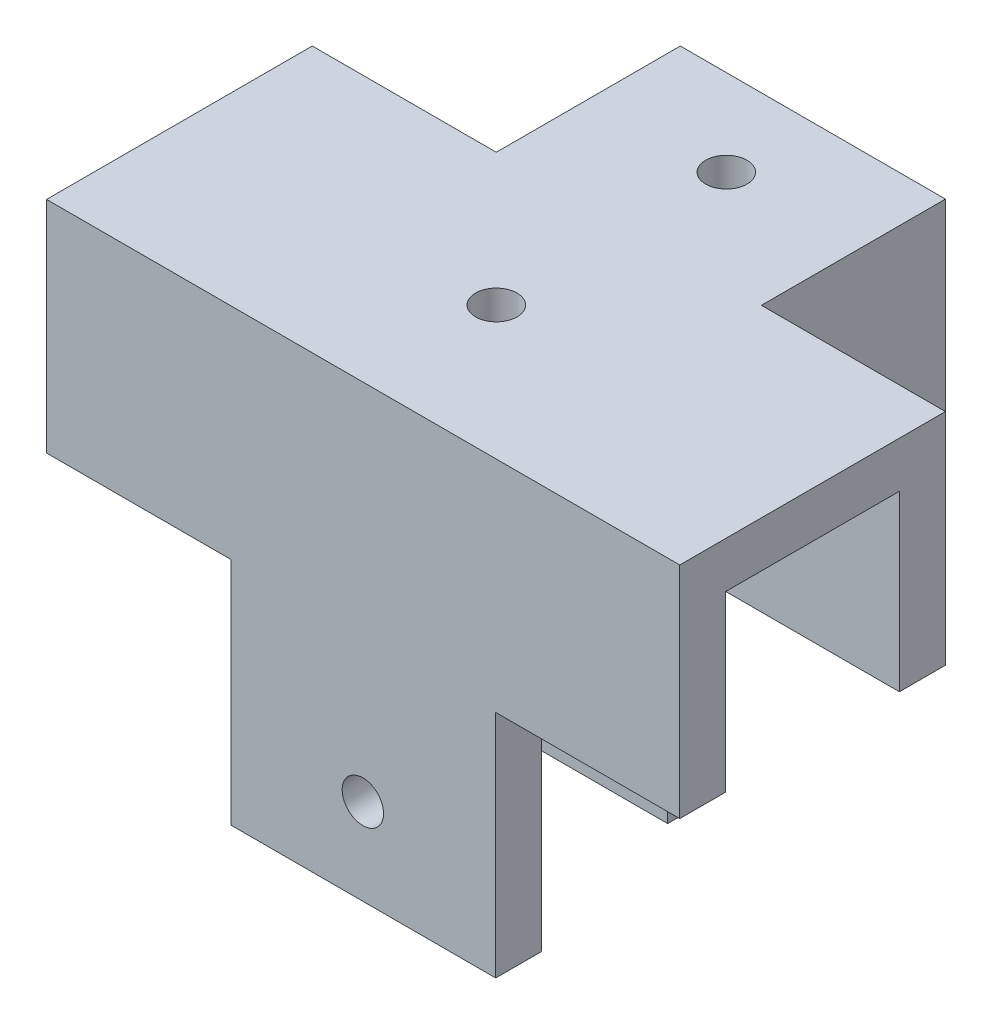
from build123d import *

# Parameters (mm, degrees)
EXTRUDE_1_DEPTH     = 15.1
EXTRUDE_1_2_DEPTH   = 15.1
SKETCH_1_W          = 55.05
SKETCH_1_H          = 4
EXTRUDE_1_3_DEPTH   = 15.1
SKETCH_2_W          = 4
SKETCH_2_H          = 16
SKETCH_2_W_2        = 19.05
EXTRUDE_2_DEPTH     = 4
EXTRUDE_3_DEPTH     = 20
SKETCH_4_R          = 1.8
CUT_EXTRUDE_1_DEPTH = 20
SKETCH_5_R          = 1.8
CUT_EXTRUDE_2_DEPTH = 27


with BuildPart() as part:
    # 草图1 → 凸台-拉伸1 (new body)
    with BuildSketch(Plane(origin=(0, 0, 0), x_dir=(1, 0, 0), z_dir=(0, 1, 0))):
        Polygon((-6.030769231, 9.384615385), (-22.030769231, 9.384615385), (-22.030769231, 5.384615385), (-6.030769231, 5.384615385), (-2.030769231, 5.384615385), (-2.030769231, 9.384615385), (-2.030769231, 25.384615385), (-6.030769231, 25.384615385), align=None)
    extrude(amount=EXTRUDE_1_DEPTH)



with BuildPart() as body_2:
    # 草图1 → Extrude 1 2 (new body)
    with BuildSketch(Plane(origin=(0, 0, 0), x_dir=(1, 0, 0), z_dir=(0, 1, 0))):
        Polygon((22.665384615, 5.384615385), (33.019230769, 5.384615385), (33.019230769, 9.384615385), (17.019230769, 9.384615385), (17.019230769, 25.384615385), (13.019230769, 25.384615385), (13.019230769, 8.769230769), (13.019230769, 5.384615385), align=None)
    extrude(amount=EXTRUDE_1_2_DEPTH)


with BuildPart() as body_3:
    # 草图1 → Extrude 1 3 (new body)
    with BuildSketch(Plane(origin=(0, 0, 0), x_dir=(1, 0, 0), z_dir=(0, 1, 0))):
        with Locations((5.494230769, -11.715384615)):
            Rectangle(SKETCH_1_W, SKETCH_1_H)
    extrude(amount=EXTRUDE_1_3_DEPTH)


with BuildPart() as part_1:
    add(part.part)

    add(body_2.part)  # 凸台-拉伸2 merges body 2

    add(body_3.part)  # 凸台-拉伸2 merges body 3
    # 草图2 → 凸台-拉伸2 (add)
    with BuildSketch(Plane(origin=(0, 15.1, 0), x_dir=(1, 0, 0), z_dir=(0, 1, 0))):
        with Locations((-4.030769231, 17.384615385)):
            Rectangle(SKETCH_2_W, SKETCH_2_H)
        with Locations((7.494230769, 17.384615385)):
            Rectangle(SKETCH_2_W_2, SKETCH_2_H)
        Polygon((-2.030769231, 5.384615385), (-22.030769231, 5.384615385), (-22.030769231, -13.715384615), (33.019230769, -13.715384615), (33.019230769, 9.384615385), (17.019230769, 9.384615385), (-2.030769231, 9.384615385), align=None)
        Polygon((-6.030769231, 9.384615385), (-22.030769231, 9.384615385), (-22.030769231, 5.384615385), (-2.030769231, 5.384615385), (-2.030769231, 9.384615385), align=None)
    extrude(amount=EXTRUDE_2_DEPTH)

    # 草图3 → 凸台-拉伸3 (add)
    with BuildSketch(Plane.XZ):
        Polygon((12.869230769, -9.384615385), (-5.980769231, -9.384615385), (-5.980769231, 13.715384615), (17.019230769, 13.715384615), (17.019230769, 9.715384615), (13.019230769, 9.715384615), (-2.130769231, 9.715384615), (-2.130769231, -5.384615385), (12.869230769, -5.384615385), align=None)
    extrude(amount=EXTRUDE_3_DEPTH)

    # 草图4 → 切除-拉伸1 (cut)
    with BuildSketch(Plane(origin=(0, 19.1, 0), x_dir=(1, 0, 0), z_dir=(0, 1, 0))):
        with Locations((5.469230769, 17.884615385)):
            Circle(SKETCH_4_R)
        with Locations((5.469230769, -2.115384615)):
            Circle(SKETCH_4_R)
    extrude(amount=-CUT_EXTRUDE_1_DEPTH, mode=Mode.SUBTRACT)

    # 草图5 → 切除-拉伸2 (cut)
    with BuildSketch(Plane.XY.offset(13.715384615)):
        with Locations((5.469230769, -12.5)):
            Circle(SKETCH_5_R)
    extrude(amount=-CUT_EXTRUDE_2_DEPTH, mode=Mode.SUBTRACT)


solid = part_1.part
